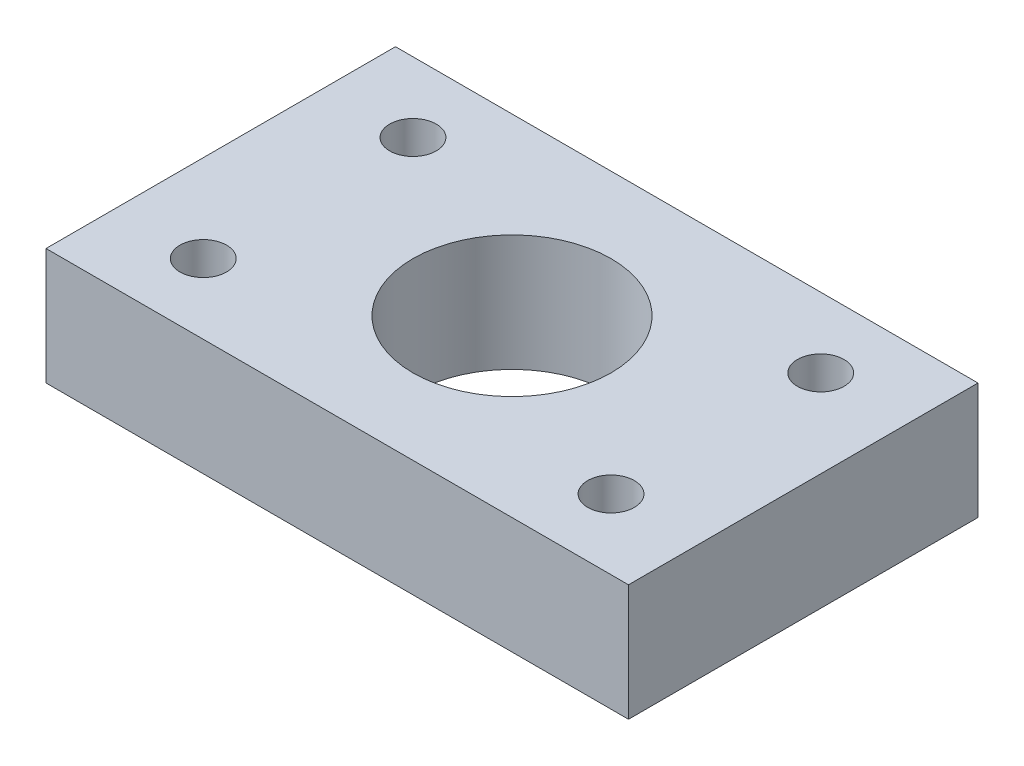
from build123d import *

# Parameters (mm, degrees)
SKETCH1_W           = 50
SKETCH1_H           = 30
SKETCH1_R           = 8.5
SKETCH1_R_2         = 2
BOSS_EXTRUDE1_DEPTH = 10


with BuildPart() as part:
    # Sketch1 → Boss-Extrude1 (new body)
    with BuildSketch(Plane(origin=(0, 0, 0), x_dir=(1, 0, 0), z_dir=(0, 1, 0))):
        Rectangle(SKETCH1_W, SKETCH1_H)
        Circle(SKETCH1_R, mode=Mode.SUBTRACT)
        with Locations((-17.5, 9)):
            Circle(SKETCH1_R_2, mode=Mode.SUBTRACT)
        with Locations((17.5, 9)):
            Circle(SKETCH1_R_2, mode=Mode.SUBTRACT)
        with Locations((17.5, -9)):
            Circle(SKETCH1_R_2, mode=Mode.SUBTRACT)
        with Locations((-17.5, -9)):
            Circle(SKETCH1_R_2, mode=Mode.SUBTRACT)
    extrude(amount=BOSS_EXTRUDE1_DEPTH)


solid = part.part
